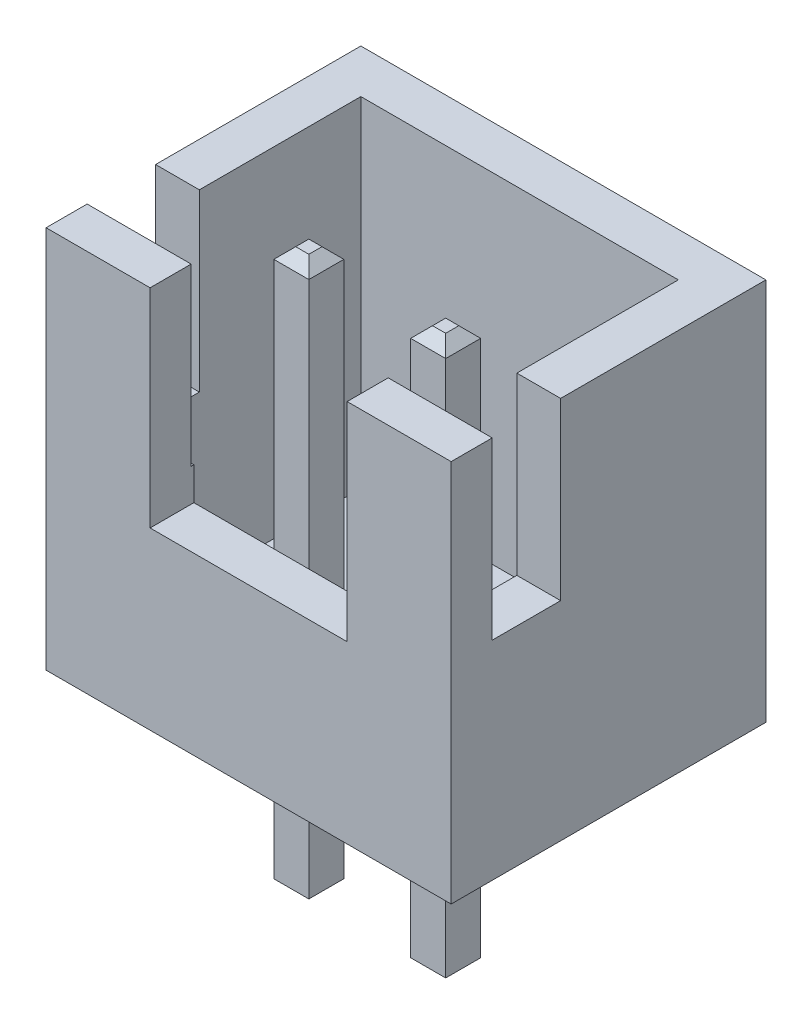
from build123d import *

# Parameters (mm, degrees)
SKETCH1_W                = 7.4
SKETCH1_H                = 5.75
BOSS_EXTRUDE1_DEPTH      = 7
SHELL1_T                 = -0.8
SKETCH2_W                = 1.25
SKETCH2_H                = 3.2
CUT_EXTRUDE1_DEPTH       = 8.4
CUT_EXTRUDE2_REACH       = 7.75
SKETCH3_W                = 3.6
SKETCH3_H                = 3.8
SKETCH4_W                = 0.64
SKETCH4_H                = 0.64
BOSS_EXTRUDE2_DEPTH      = 3.45
BOSS_EXTRUDE2_DEPTH_BACK = 6.75
CHAMFER1_SIZE            = 0.2


with BuildPart() as part:
    # Sketch1 → Boss-Extrude1 (new body)
    with BuildSketch(Plane(origin=(0, 0, 0), x_dir=(1, 0, 0), z_dir=(0, 1, 0))):
        Rectangle(SKETCH1_W, SKETCH1_H)
    extrude(amount=BOSS_EXTRUDE1_DEPTH)

    # Shell1
    shell1_openings = [part.faces().sort_by_distance(p)[0] for p in [
        (0, 7, 0),
    ]]
    offset(amount=SHELL1_T, openings=shell1_openings, kind=Kind.INTERSECTION)

    # Sketch2 → Cut-Extrude1 (cut, through all)
    with BuildSketch(Plane(origin=(3.7, 0, 0), x_dir=(0, 0, -1), z_dir=(1, 0, 0))):
        with Locations((-1.5, 5.4)):
            Rectangle(SKETCH2_W, SKETCH2_H)
    extrude(amount=-CUT_EXTRUDE1_DEPTH, mode=Mode.SUBTRACT)

    # Sketch3 → Cut-Extrude2 (cut, up to next)
    with BuildSketch(Plane.XY.offset(2.875), mode=Mode.PRIVATE) as cut_extrude2_sk1:
        with Locations((0, 5.1)):
            Rectangle(SKETCH3_W, SKETCH3_H)
    cut_extrude2_tool1 = extrude(cut_extrude2_sk1.sketch, amount=-CUT_EXTRUDE2_REACH, mode=Mode.PRIVATE) & part.part
    add(cut_extrude2_tool1.solids().sort_by_distance((0, 5.1, 2.875))[0], mode=Mode.SUBTRACT)

    # Sketch4 → Boss-Extrude2 (add, two sides)
    with BuildSketch(Plane.XZ) as boss_extrude2_sk:
        with Locations((-1.25, 0.525)):
            Rectangle(SKETCH4_W, SKETCH4_H)
        with Locations((1.25, 0.525)):
            Rectangle(SKETCH4_W, SKETCH4_H)
    extrude(amount=BOSS_EXTRUDE2_DEPTH)
    extrude(boss_extrude2_sk.sketch, amount=-BOSS_EXTRUDE2_DEPTH_BACK)

    # Chamfer1
    chamfer1_edges = [part.edges().sort_by_distance(p)[0] for p in [
        (-0.93, 6.75, 0.525),
        (-1.25, 6.75, 0.205),
        (-1.57, 6.75, 0.525),
        (-1.25, 6.75, 0.845),
        (-0.93, -3.45, 0.525),
        (-1.25, -3.45, 0.845),
        (-1.57, -3.45, 0.525),
        (-1.25, -3.45, 0.205),
        (1.25, 6.75, 0.845),
        (1.57, 6.75, 0.525),
        (1.25, 6.75, 0.205),
        (0.93, 6.75, 0.525),
        (1.25, -3.45, 0.845),
        (0.93, -3.45, 0.525),
        (1.25, -3.45, 0.205),
        (1.57, -3.45, 0.525),
    ]]
    chamfer(chamfer1_edges, length=CHAMFER1_SIZE)


solid = part.part
